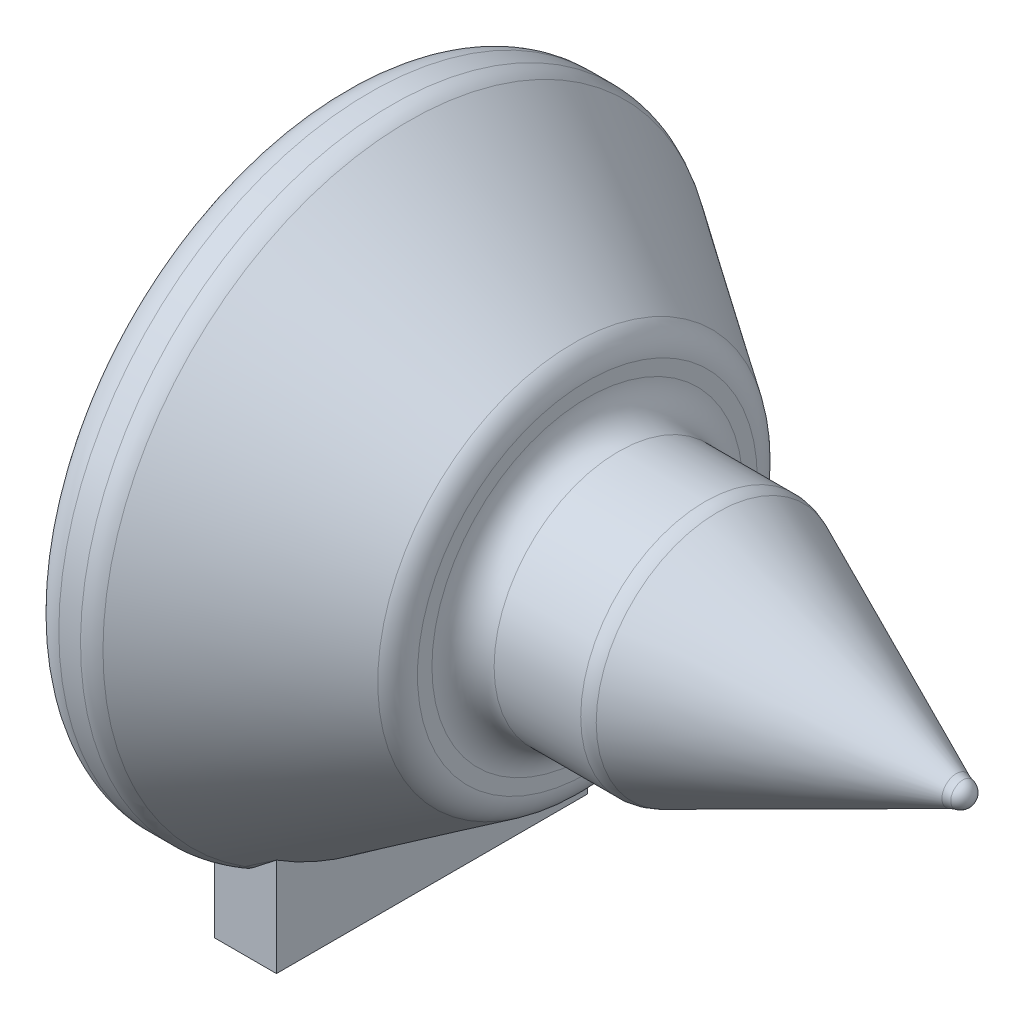
from build123d import *

# Parameters (mm, degrees)
FILLET1_R           = 5
FILLET2_R           = 5
FILLET3_R           = 2
SKETCH3_W           = 10
SKETCH3_H           = 5
BOSS_EXTRUDE1_DEPTH = 25
BOSS_EXTRUDE2_REACH = 153.483
SKETCH4_W           = 10
SKETCH4_H           = 50


with BuildPart() as part:
    # Sketch1 → Revolve1 (revolve)
    with BuildSketch(Plane.XY, mode=Mode.PRIVATE) as revolve1_sk:
        Polygon((0, -50), (10, -50), (40, -30), (40, 0), (20, 0), (20, -25), (0, -25), align=None)
    revolve(revolve1_sk.sketch.rotate(Axis((-91.89476197, 0, 0), (1, 0, 0)), 270), axis=Axis((-91.89476197, 0, 0), (1, 0, 0)))

    # Sketch2 → Revolve3 (revolve)
    with BuildSketch(Plane.XY):
        with BuildLine():
            Line((40, -20), (60, -20))
            Line((60, -20), (100, -2))
            ThreePointArc((100, -2), (101.414213562, -1.414213562), (102, 0))
            Line((102, 0), (100, 0))
            Line((100, 0), (40, 0))
            Line((40, 0), (40, -20))
        make_face()
    revolve(axis=Axis((100, 0, 0), (-1, 0, 0)))

    # Fillet1
    fillet1_edges = [part.edges().sort_by_distance(p)[0] for p in [
        (40, 20, 0),
        (60, 20, 0),
        (40, 0, -30),
        (10, 0, -50),
        (0, 0, -50),
    ]]
    fillet(fillet1_edges, radius=FILLET1_R)

    # Fillet2
    fillet2_edges = [part.edges().sort_by_distance(p)[0] for p in [
        (100, 2, 0),
    ]]
    fillet(fillet2_edges, radius=FILLET2_R)

    # Fillet3
    fillet3_edges = [part.edges().sort_by_distance(p)[0] for p in [
        (0, 0, -25),
    ]]
    fillet(fillet3_edges, radius=FILLET3_R)

    # Sketch4 → Boss-Extrude2 (add, up to next)
    with BuildSketch(Plane(origin=(0, -50.215600765, 0), x_dir=(1, 0, 0), z_dir=(0, 1, 0)), mode=Mode.PRIVATE) as boss_extrude2_sk1:
        with Locations((10, 0)):
            Rectangle(SKETCH4_W, SKETCH4_H)
    boss_extrude2_tool1 = extrude(boss_extrude2_sk1.sketch, amount=BOSS_EXTRUDE2_REACH, mode=Mode.PRIVATE) - part.part


with BuildPart() as body_2:
    # Sketch3 → Boss-Extrude1 (new, symmetric)
    with BuildSketch(Plane.XY):
        with Locations((10, -52.715600765)):
            Rectangle(SKETCH3_W, SKETCH3_H)
    extrude(amount=BOSS_EXTRUDE1_DEPTH, both=True)


with BuildPart() as part_1:
    add(part.part)

    add(body_2.part)  # Boss-Extrude2 merges body 2
    add(boss_extrude2_tool1.solids().sort_by_distance((10, -50.215601, 0))[0])


solid = part_1.part
